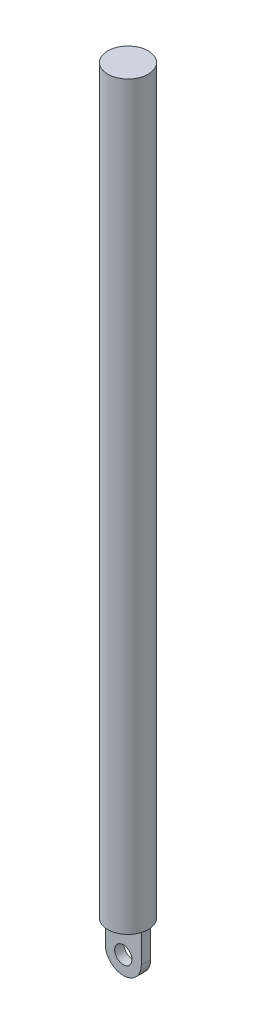
from build123d import *

# Parameters (mm, degrees)
SKETCH1_R           = 3.395
BOSS_EXTRUDE1_DEPTH = 124.37
SKETCH3_W           = 6.05
SKETCH3_H           = 0.785
BOSS_EXTRUDE2_DEPTH = 7.98
CUT_EXTRUDE1_DEPTH  = 7.98
SKETCH5_R           = 1.45
CUT_EXTRUDE2_DEPTH  = 7.98


with BuildPart() as part:
    # Sketch1 → Boss-Extrude1 (new body)
    with BuildSketch(Plane(origin=(0, 0, 0), x_dir=(1, 0, 0), z_dir=(0, 1, 0))):
        Circle(SKETCH1_R)
    extrude(amount=BOSS_EXTRUDE1_DEPTH)

    # Sketch3 → Boss-Extrude2 (add)
    with BuildSketch(Plane(origin=(0, 0, 0), x_dir=(1, 0, 0), z_dir=(0, 1, 0))):
        with Locations((0, 0.3925)):
            Rectangle(SKETCH3_W, SKETCH3_H)
        with Locations((0, -0.3925)):
            Rectangle(SKETCH3_W, SKETCH3_H)
    extrude(amount=-BOSS_EXTRUDE2_DEPTH)

    # Sketch4 → Cut-Extrude1 (cut)
    with BuildSketch(Plane(origin=(0, 0, -0.785), x_dir=(-1, 0, 0), z_dir=(0, 0, -1))):
        with BuildLine():
            Line((-3.025, -4.955), (-5.551253647, -4.955))
            Line((-5.551253647, -4.955), (-3.356299124, -8.834088681))
            Line((-3.356299124, -8.834088681), (4.987206478, -9.531994941))
            Line((4.987206478, -9.531994941), (4.886235873, -4.955))
            Line((4.886235873, -4.955), (3.025, -4.955))
            ThreePointArc((3.025, -4.955), (0, -7.98), (-3.025, -4.955))
        make_face()
    extrude(amount=-CUT_EXTRUDE1_DEPTH, mode=Mode.SUBTRACT)

    # Sketch5 → Cut-Extrude2 (cut)
    with BuildSketch(Plane(origin=(0, 0, -0.785), x_dir=(-1, 0, 0), z_dir=(0, 0, -1))):
        with Locations((0, -4.955)):
            Circle(SKETCH5_R)
    extrude(amount=-CUT_EXTRUDE2_DEPTH, mode=Mode.SUBTRACT)


solid = part.part
